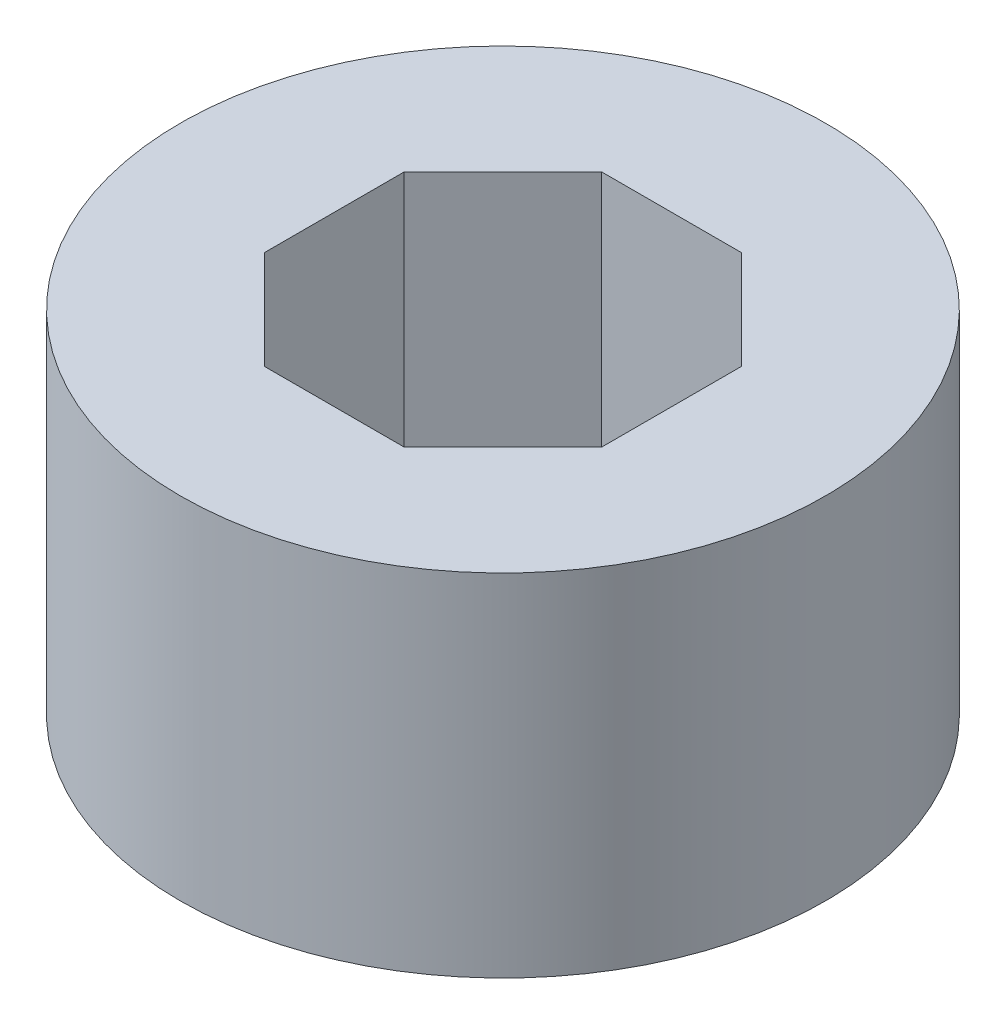
from build123d import *

# Parameters (mm, degrees)
SKETCH1_R           = 4.6
BOSS_EXTRUDE1_DEPTH = 5


with BuildPart() as part:
    # Sketch1 → Boss-Extrude1 (new body)
    with BuildSketch(Plane(origin=(0, 0, 0), x_dir=(1, 0, 0), z_dir=(0, 1, 0))):
        Circle(SKETCH1_R)
        Polygon((-0.994976924, 2.402086785), (-2.402086785, 0.994976924), (-2.402086785, -0.994976924), (-0.994976924, -2.402086785), (0.994976924, -2.402086785), (2.402086785, -0.994976924), (2.402086785, 0.994976924), (0.994976924, 2.402086785), align=None, mode=Mode.SUBTRACT)
    extrude(amount=BOSS_EXTRUDE1_DEPTH)


solid = part.part
